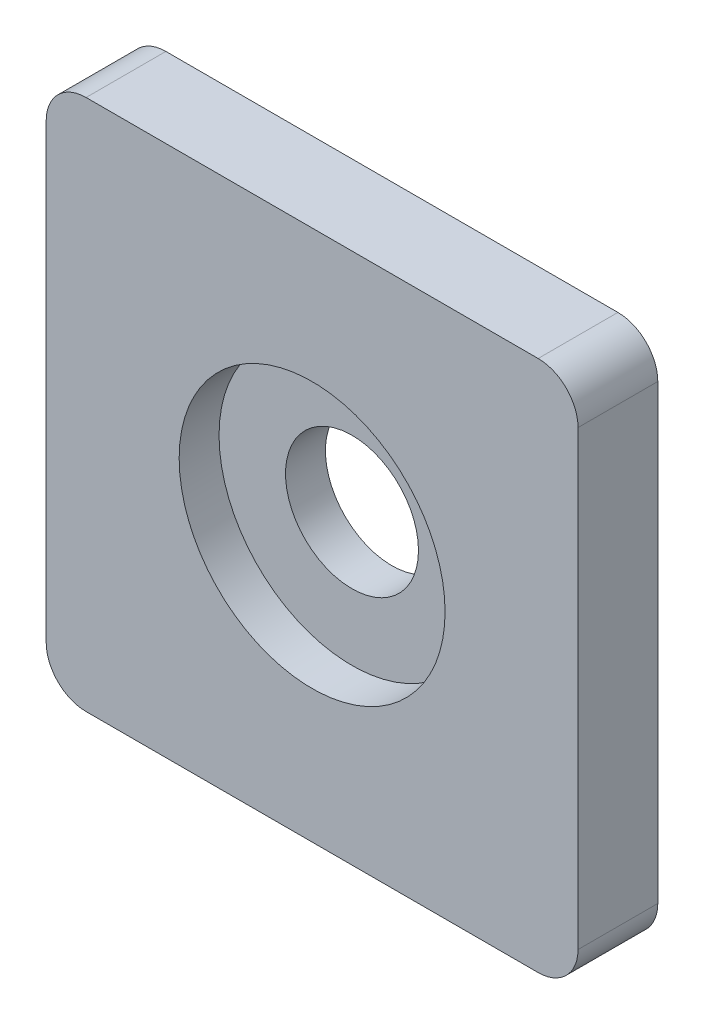
from build123d import *

# Parameters (mm, degrees)
SKETCH1_W           = 20
SKETCH1_H           = 20
SKETCH1_R           = 2.5
BOSS_EXTRUDE1_DEPTH = 3
SKETCH2_R           = 5
CUT_EXTRUDE1_DEPTH  = 1.5
FILLET1_R           = 1.5


with BuildPart() as part:
    # Sketch1 → Boss-Extrude1 (new body)
    with BuildSketch(Plane.XY):
        Rectangle(SKETCH1_W, SKETCH1_H)
        Circle(SKETCH1_R, mode=Mode.SUBTRACT)
    extrude(amount=BOSS_EXTRUDE1_DEPTH)

    # Sketch2 → Cut-Extrude1 (cut)
    with BuildSketch(Plane.XY.offset(3)):
        Circle(SKETCH2_R)
    extrude(amount=-CUT_EXTRUDE1_DEPTH, mode=Mode.SUBTRACT)

    # Fillet1
    fillet1_edges = [part.edges().sort_by_distance(p)[0] for p in [
        (-10, 10, 1.5),
        (10, 10, 1.5),
        (10, -10, 1.5),
        (-10, -10, 1.5),
    ]]
    fillet(fillet1_edges, radius=FILLET1_R)


solid = part.part
